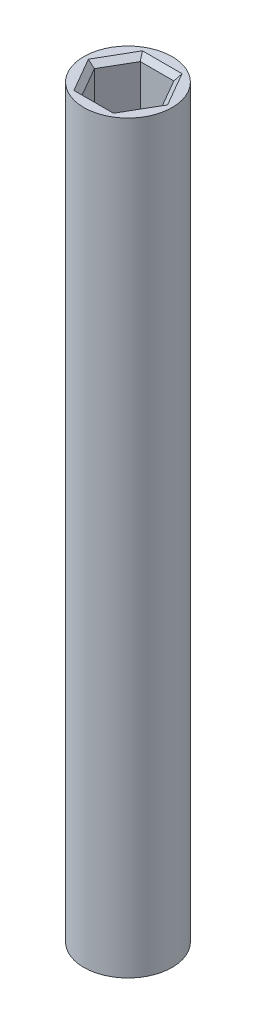
from build123d import *

# Parameters (mm, degrees)
SKETCH1_R           = 4.25
BOSS_EXTRUDE1_DEPTH = 71.68750559
CUT_EXTRUDE1_DEPTH  = 6.6
CHAMFER1_SIZE       = 0.5
CUT_EXTRUDE2_DEPTH  = 6.6
CHAMFER2_SIZE       = 0.5


with BuildPart() as part:
    # Sketch1 → Boss-Extrude1 (new body)
    with BuildSketch(Plane(origin=(0, 0, 0), x_dir=(1, 0, 0), z_dir=(0, 1, 0))):
        Circle(SKETCH1_R)
    extrude(amount=BOSS_EXTRUDE1_DEPTH)

    # Sketch2 → Cut-Extrude1 (cut)
    with BuildSketch(Plane(origin=(0, 71.68750559, 0), x_dir=(1, 0, 0), z_dir=(0, 1, 0))):
        Polygon((1.616580754, 2.8), (-1.616580754, 2.8), (-3.233161507, 0), (-1.616580754, -2.8), (1.616580754, -2.8), (3.233161507, 0), align=None)
    extrude(amount=-CUT_EXTRUDE1_DEPTH, mode=Mode.SUBTRACT)

    # Chamfer1
    chamfer1_edges = [part.edges().sort_by_distance(p)[0] for p in [
        (2.424871131, 71.68750559, -1.4),
        (0, 71.68750559, -2.8),
        (-2.424871131, 71.68750559, -1.4),
        (-2.424871131, 71.68750559, 1.4),
        (0, 71.68750559, 2.8),
        (2.424871131, 71.68750559, 1.4),
    ]]
    chamfer(chamfer1_edges, length=CHAMFER1_SIZE)

    # Sketch3 → Cut-Extrude2 (cut)
    with BuildSketch(Plane.XZ):
        Polygon((0, 3.233161507), (-2.8, 1.616580754), (-2.8, -1.616580754), (0, -3.233161507), (2.8, -1.616580754), (2.8, 1.616580754), align=None)
    extrude(amount=-CUT_EXTRUDE2_DEPTH, mode=Mode.SUBTRACT)

    # Chamfer2
    chamfer2_edges = [part.edges().sort_by_distance(p)[0] for p in [
        (1.4, 0, 2.424871131),
        (-1.4, 0, 2.424871131),
        (-2.8, 0, 0),
        (-1.4, 0, -2.424871131),
        (1.4, 0, -2.424871131),
        (2.8, 0, 0),
    ]]
    chamfer(chamfer2_edges, length=CHAMFER2_SIZE)


solid = part.part
